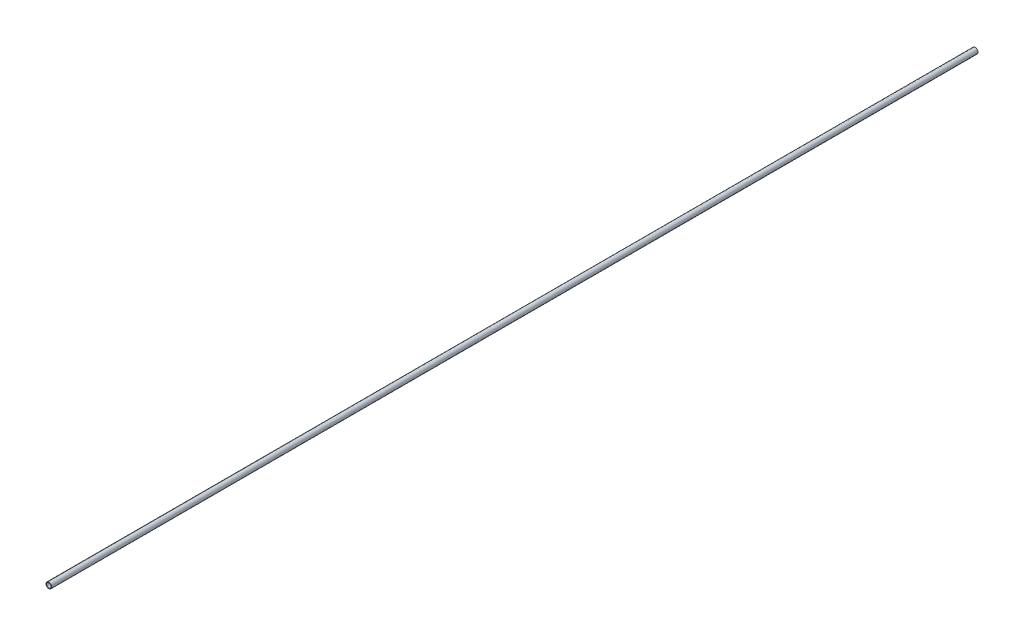
from build123d import *

# Parameters (mm, degrees)
PIPESKETCH_R    = 16.764
PIPESKETCH_R_2  = 13.3858
EXTRUSION_DEPTH = 5486.4


with BuildPart() as part:
    # PipeSketch → Extrusion (new body)
    with BuildSketch(Plane.XY):
        Circle(PIPESKETCH_R)
        Circle(PIPESKETCH_R_2, mode=Mode.SUBTRACT)
    extrude(amount=EXTRUSION_DEPTH)


solid = part.part
